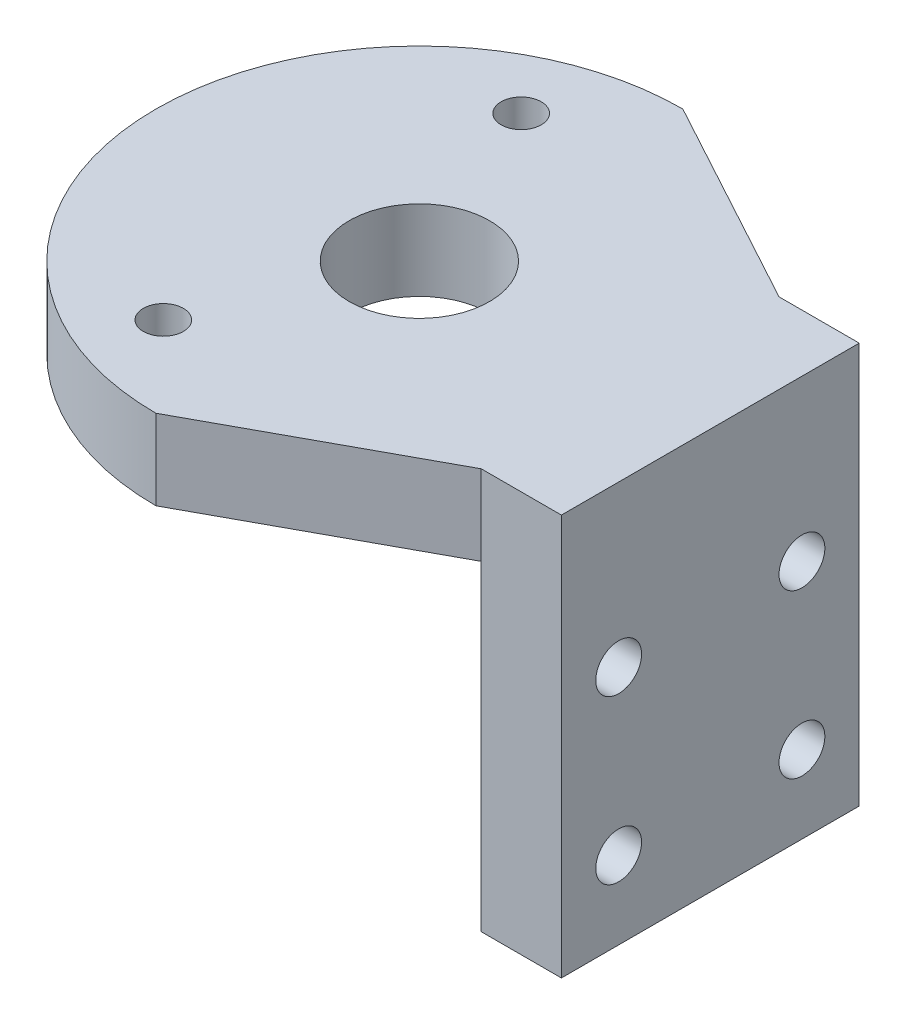
from build123d import *

# Parameters (mm, degrees)
BOSS_EXTRUDE1_DEPTH = 7
SKETCH2_W           = 7
SKETCH2_H           = 46
BOSS_EXTRUDE2_DEPTH = 28
SKETCH4_R           = 6.125
CUT_EXTRUDE1_DEPTH  = 7
SKETCH5_R           = 1.75
CUT_EXTRUDE3_DEPTH  = 7
SKETCH6_W           = 10
SKETCH6_H           = 28
CUT_EXTRUDE4_DEPTH  = 10
CUT_EXTRUDE5_DEPTH  = 10
SKETCH8_R           = 2
CUT_EXTRUDE6_DEPTH  = 10


with BuildPart() as part:
    # Sketch1 → Boss-Extrude1 (new body)
    with BuildSketch(Plane(origin=(0, 0, 0), x_dir=(1, 0, 0), z_dir=(0, 1, 0))):
        with BuildLine():
            Line((25.4, 23), (25.4, -23))
            Line((25.4, -23), (0, -23))
            ThreePointArc((0, -23), (-23, 0), (0, 23))
            Line((0, 23), (25.4, 23))
        make_face()
    extrude(amount=-BOSS_EXTRUDE1_DEPTH)

    # Sketch2 → Boss-Extrude2 (add)
    with BuildSketch(Plane.XZ.offset(7)):
        with Locations((21.9, 0)):
            Rectangle(SKETCH2_W, SKETCH2_H)
    extrude(amount=BOSS_EXTRUDE2_DEPTH)

    # Sketch4 → Cut-Extrude1 (cut)
    with BuildSketch(Plane(origin=(0, 0, 0), x_dir=(1, 0, 0), z_dir=(0, 1, 0))):
        Circle(SKETCH4_R)
    extrude(amount=-CUT_EXTRUDE1_DEPTH, mode=Mode.SUBTRACT)

    # Sketch5 → Cut-Extrude3 (cut)
    with BuildSketch(Plane(origin=(0, 0, 0), x_dir=(1, 0, 0), z_dir=(0, 1, 0))):
        with Locations((-6.731, 15.621)):
            Circle(SKETCH5_R)
        with Locations((-6.731, -15.621)):
            Circle(SKETCH5_R)
    extrude(amount=-CUT_EXTRUDE3_DEPTH, mode=Mode.SUBTRACT)

    # Sketch6 → Cut-Extrude4 (cut)
    with BuildSketch(Plane.ZY.offset(-18.4)):
        with Locations((18, -21)):
            Rectangle(SKETCH6_W, SKETCH6_H)
        with Locations((-18, -21)):
            Rectangle(SKETCH6_W, SKETCH6_H)
    extrude(amount=-CUT_EXTRUDE4_DEPTH, mode=Mode.SUBTRACT)

    # Sketch7 → Cut-Extrude5 (cut)
    with BuildSketch(Plane.XZ.offset(7)):
        Polygon((0, -23), (18.4, -13), (25.4, -13), (25.4, -23), align=None)
        Polygon((0, 23), (18.4, 13), (25.4, 13), (25.4, 23), align=None)
    extrude(amount=-CUT_EXTRUDE5_DEPTH, mode=Mode.SUBTRACT)

    # Sketch8 → Cut-Extrude6 (cut)
    with BuildSketch(Plane.ZY.offset(-18.4)):
        with Locations((-8, -14)):
            Circle(SKETCH8_R)
        with Locations((8, -14)):
            Circle(SKETCH8_R)
        with Locations((-8, -28.225)):
            Circle(SKETCH8_R)
        with Locations((8, -28.225)):
            Circle(SKETCH8_R)
    extrude(amount=-CUT_EXTRUDE6_DEPTH, mode=Mode.SUBTRACT)


solid = part.part
